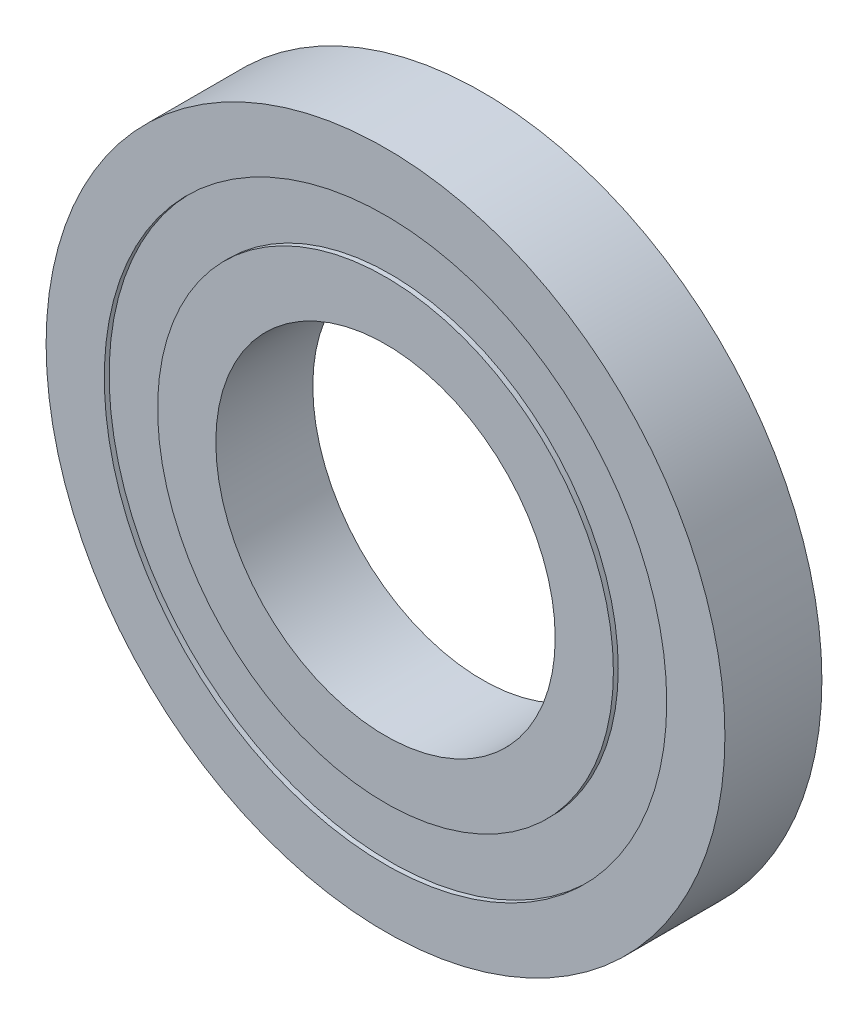
from build123d import *

# Parameters (mm, degrees)
SKETCH1_R             = 35
SKETCH1_R_2           = 29
BOSS_EXTRUDE1_DEPTH   = 10
SKETCH1_R_3           = 23.5
SKETCH1_R_4           = 17.5
BOSS_EXTRUDE1_2_DEPTH = 10
BOSS_EXTRUDE2_START   = 0.5
SKETCH1_3_R           = 29
SKETCH1_3_R_2         = 23.5
BOSS_EXTRUDE2_DEPTH   = 9


with BuildPart() as part:
    # Sketch1 → Boss-Extrude1 (new body)
    with BuildSketch(Plane(origin=(0, 0, 0), x_dir=(0, 1, 0), z_dir=(0, 0, 1))):
        Circle(SKETCH1_R)
        Circle(SKETCH1_R_2, mode=Mode.SUBTRACT)
    extrude(amount=BOSS_EXTRUDE1_DEPTH)



with BuildPart() as body_2:
    # Sketch1 → Boss-Extrude1 2 (new body)
    with BuildSketch(Plane(origin=(0, 0, 0), x_dir=(0, 1, 0), z_dir=(0, 0, 1))):
        Circle(SKETCH1_R_3)
        Circle(SKETCH1_R_4, mode=Mode.SUBTRACT)
    extrude(amount=BOSS_EXTRUDE1_2_DEPTH)


with BuildPart() as part_1:
    add(part.part)

    add(body_2.part)  # Boss-Extrude2 merges body 2
    # Sketch1_3 → Boss-Extrude2 (add)
    with BuildSketch(Plane(origin=(0, 0, 0), x_dir=(0, 1, 0), z_dir=(0, 0, 1)).offset(BOSS_EXTRUDE2_START)):
        Circle(SKETCH1_3_R)
        Circle(SKETCH1_3_R_2, mode=Mode.SUBTRACT)
    extrude(amount=BOSS_EXTRUDE2_DEPTH)


solid = part_1.part
